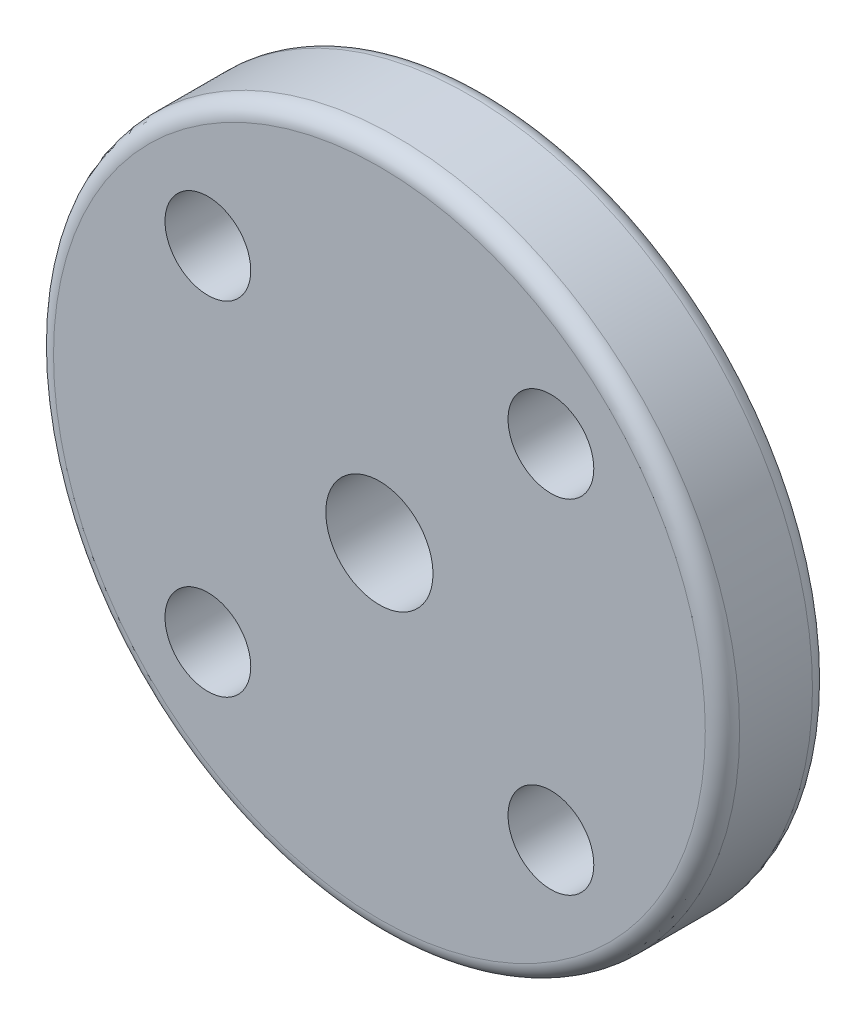
from build123d import *

# Parameters (mm, degrees)
SKETCH1_R      = 16
SKETCH1_R_2    = 2
SKETCH1_R_3    = 2.5
EXTRUDE2_DEPTH = 5
FILLET1_R      = 0.8


with BuildPart() as part:
    # Sketch1 → Extrude2 (new body)
    with BuildSketch(Plane.XY):
        Circle(SKETCH1_R)
        with Locations((-8, 8)):
            Circle(SKETCH1_R_2, mode=Mode.SUBTRACT)
        with Locations((-8, -8)):
            Circle(SKETCH1_R_2, mode=Mode.SUBTRACT)
        with Locations((8, -8)):
            Circle(SKETCH1_R_2, mode=Mode.SUBTRACT)
        with Locations((8, 8)):
            Circle(SKETCH1_R_2, mode=Mode.SUBTRACT)
        Circle(SKETCH1_R_3, mode=Mode.SUBTRACT)
    extrude(amount=EXTRUDE2_DEPTH)

    # Fillet1
    fillet1_edges = [part.edges().sort_by_distance(p)[0] for p in [
        (-16, 0, 5),
        (-16, 0, 0),
    ]]
    fillet(fillet1_edges, radius=FILLET1_R)


solid = part.part
